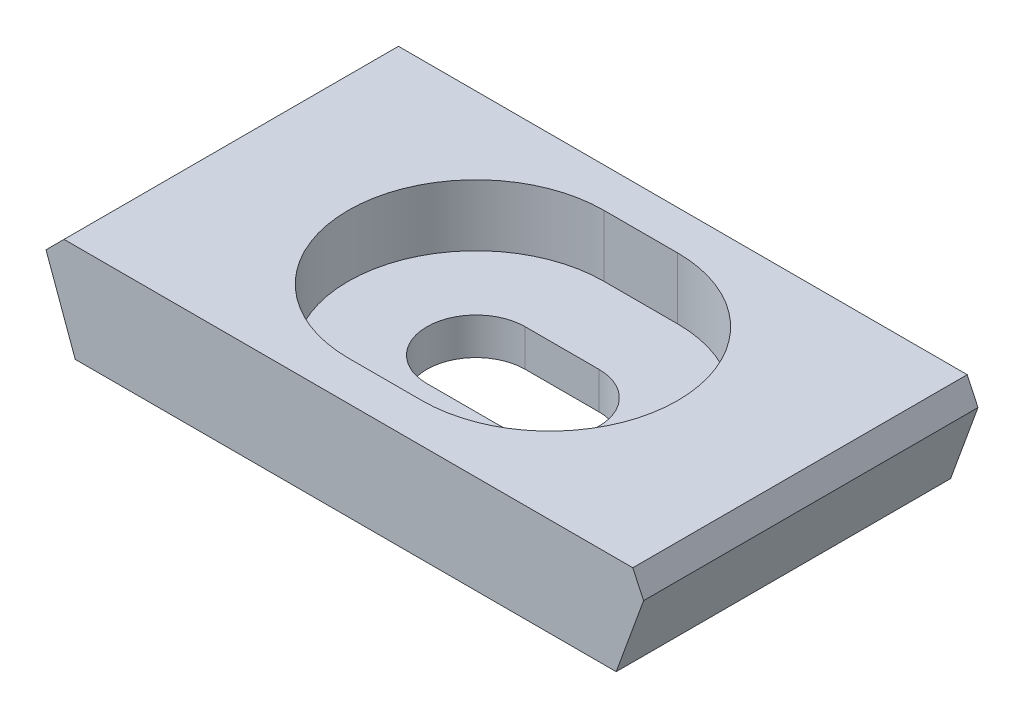
from build123d import *

# Parameters (mm, degrees)
BOSS_EXTRUDE1_DEPTH   = 17.272
SKETCH2_OUTSIDE_W     = 40.918
SKETCH2_OUTSIDE_H     = 26.552
SKETCH2_OUTSIDE_W_2   = 31.63793758
SKETCH2_OUTSIDE_H_2   = 17.272
CUT_EXTRUDE1_DEPTH    = 3.175
CUT_EXTRUDE3_DEPTH    = 2.905
CHAMFER1_SIZE2        = 1.27
CHAMFER1_SIZE         = 0.990861631
CHAMFER1_EDGE_2_SIZE2 = 1.27
CHAMFER1_EDGE_2_SIZE  = 0.990861631


with BuildPart() as part:
    # Sketch1 → Boss-Extrude1 (new body)
    with BuildSketch(Plane.XY):
        Polygon((-13.97, 0), (13.97, 0), (15.81896879, 5.08), (-15.81896879, 5.08), align=None)
    extrude(amount=BOSS_EXTRUDE1_DEPTH)

    # Sketch2 outside → Cut-Extrude1 (cut)
    with BuildSketch(Plane(origin=(0, 5.08, 0), x_dir=(1, 0, 0), z_dir=(0, 1, 0))):
        with Locations((0, -8.636)):
            Rectangle(SKETCH2_OUTSIDE_W, SKETCH2_OUTSIDE_H)
        with Locations((0, -8.636)):
            Rectangle(SKETCH2_OUTSIDE_W_2, SKETCH2_OUTSIDE_H_2, mode=Mode.SUBTRACT)
        with BuildLine():
            Line((1.905, -15.24), (-1.905, -15.24))
            ThreePointArc((-1.905, -15.24), (-8.509, -8.636), (-1.905, -2.032))
            Line((-1.905, -2.032), (1.905, -2.032))
            ThreePointArc((1.905, -2.032), (8.509, -8.636), (1.905, -15.24))
        make_face()
    extrude(amount=-CUT_EXTRUDE1_DEPTH, mode=Mode.SUBTRACT)

    # Sketch4 → Cut-Extrude3 (cut, through all)
    with BuildSketch(Plane(origin=(0, 1.905, 0), x_dir=(1, 0, 0), z_dir=(0, 1, 0))):
        with BuildLine():
            Line((1.905, -11.176), (-1.905, -11.176))
            ThreePointArc((-1.905, -11.176), (-4.445, -8.636), (-1.905, -6.096))
            Line((-1.905, -6.096), (1.905, -6.096))
            ThreePointArc((1.905, -6.096), (4.445, -8.636), (1.905, -11.176))
        make_face()
    extrude(amount=-CUT_EXTRUDE3_DEPTH, mode=Mode.SUBTRACT)

    # Chamfer1
    chamfer1_edges = [part.edges().sort_by_distance(p)[0] for p in [
        (-15.81896879, 5.08, 8.636),
    ]]
    chamfer(chamfer1_edges, length=CHAMFER1_SIZE, length2=CHAMFER1_SIZE2)

    # Chamfer1 edge 2
    chamfer1_edge_2_edges = [part.edges().sort_by_distance(p)[0] for p in [
        (15.81896879, 5.08, 8.636),
    ]]
    chamfer(chamfer1_edge_2_edges, length=CHAMFER1_EDGE_2_SIZE, length2=CHAMFER1_EDGE_2_SIZE2)


solid = part.part
